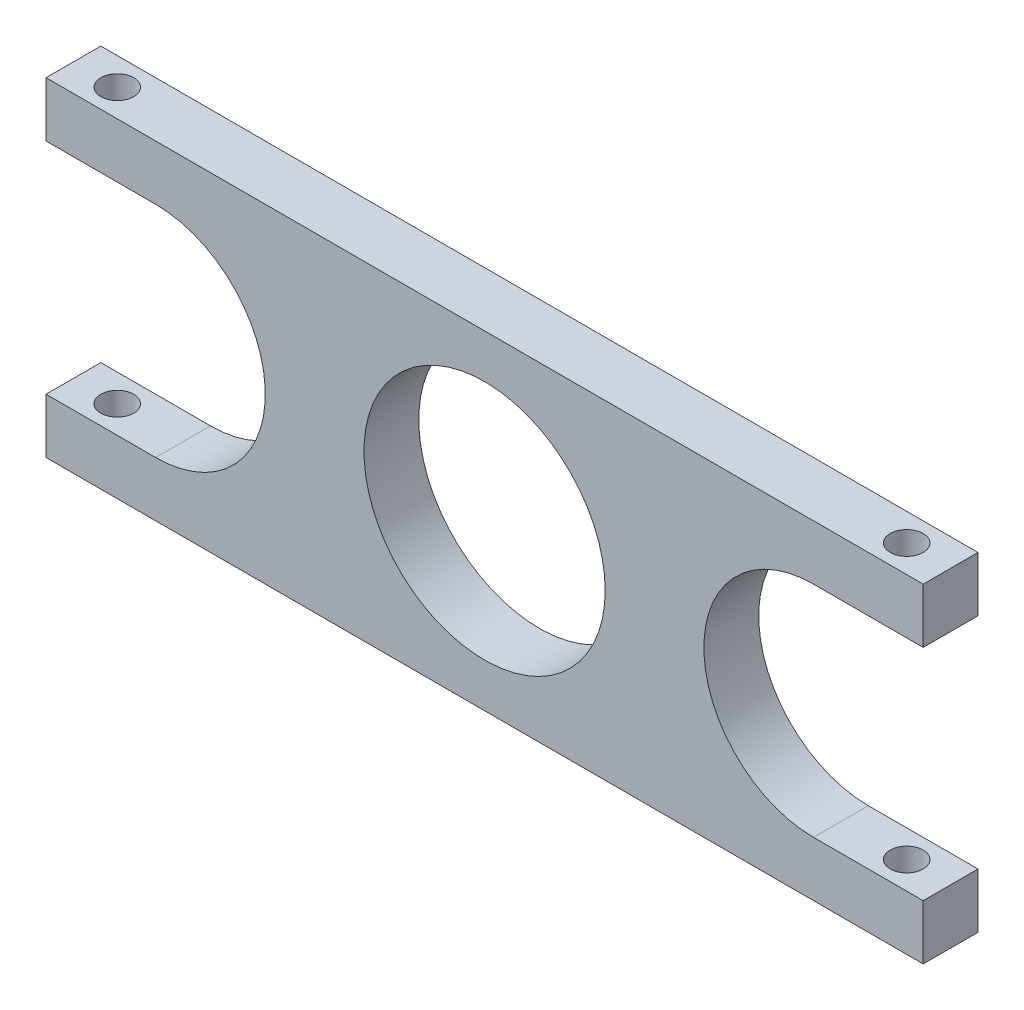
from build123d import *

# Parameters (mm, degrees)
ESQUISSE1_R        = 11
BOSS_EXTRU_1_DEPTH = 5
D_GAGEMENT_M31_D   = 3


with BuildPart() as part:
    # Esquisse1 → Boss.-Extru.1 (new body)
    with BuildSketch(Plane.XY):
        with BuildLine():
            Line((0, 0), (80, 0))
            Line((80, 0), (80, 5))
            Line((80, 5), (70, 5))
            ThreePointArc((70, 5), (60, 15), (70, 25))
            Line((70, 25), (80, 25))
            Line((80, 25), (80, 30))
            Line((80, 30), (0, 30))
            Line((0, 30), (0, 25))
            Line((0, 25), (10, 25))
            ThreePointArc((10, 25), (20, 15), (10, 5))
            Line((10, 5), (0, 5))
            Line((0, 5), (0, 0))
        make_face()
        with Locations((40, 15)):
            Circle(ESQUISSE1_R, mode=Mode.SUBTRACT)
    extrude(amount=BOSS_EXTRU_1_DEPTH)

    # Dégagement M31 (through all)
    with Locations(Plane(origin=(0, 30, 0), x_dir=(1, 0, 0), z_dir=(0, 1, 0))):
        with Locations((4, -2.5), (76, -2.5)):
            Hole(D_GAGEMENT_M31_D / 2)


solid = part.part
